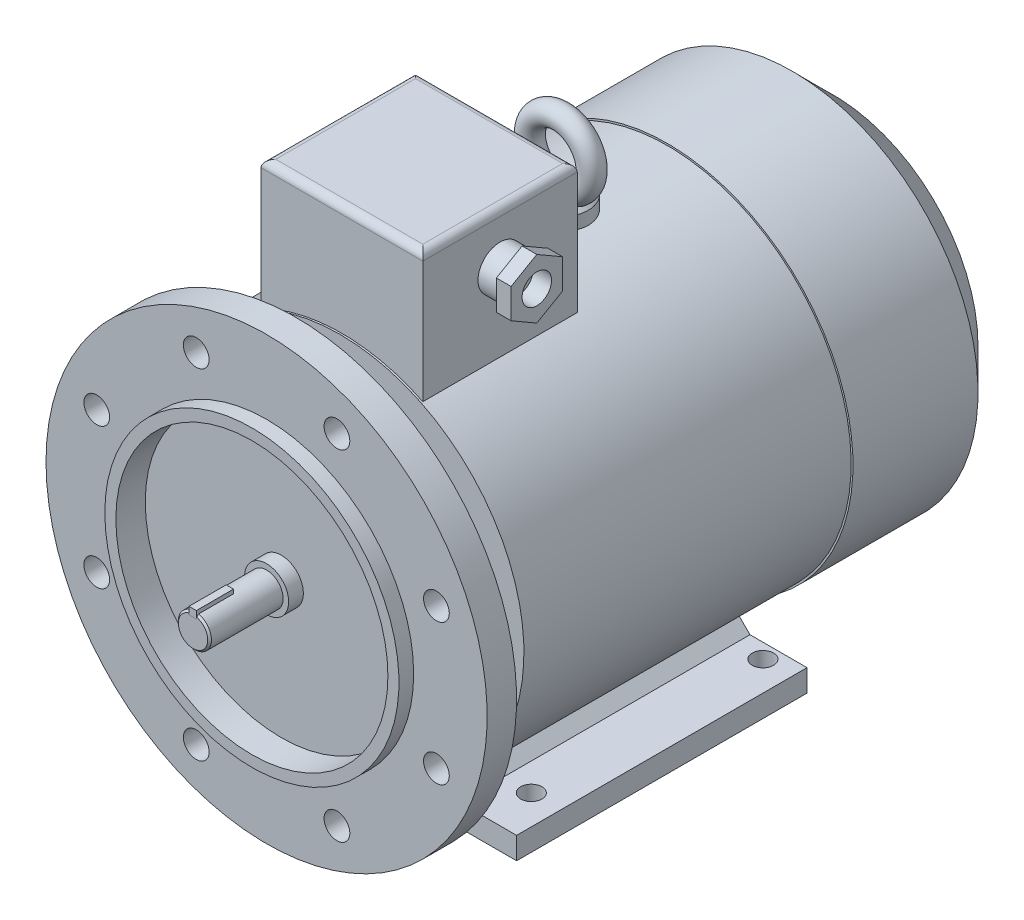
from build123d import *

# Parameters (mm, degrees)
SKETCH_1_R            = 4.5
EXTRUDE_1_DEPTH       = 20
CHAMFER_1_SIZE        = 0.5
SKETCH_2_W            = 2
SKETCH_2_H            = 2
EXTRUDE_2_DEPTH       = 0.1
EXTRUDE_2_DEPTH_BACK  = 10
SKETCH_3_R            = 6
EXTRUDE_3_DEPTH       = 4
CHAMFER_2_SIZE        = 0.5
SKETCH_4_R            = 40
SKETCH_4_R_2          = 37
EXTRUDE_4_DEPTH       = 8
SKETCH_5_R            = 60
EXTRUDE_5_DEPTH       = 4
EXTRUDE_5_DEPTH_BACK  = 4
SKETCH_6_R            = 3.5
CUT_EXTRUDE_1_DEPTH   = 29.1
SKETCH_7_R            = 42
EXTRUDE_6_DEPTH       = 12
SKETCH_8_R            = 50
EXTRUDE_7_DEPTH       = 89
SKETCH_9_R            = 50.5
EXTRUDE_8_DEPTH       = 45
CHAMFER_3_SIZE        = 11
EXTRUDE_9_DEPTH       = 79
CUT_EXTRUDE_2_REACH   = 112
SKETCH_12_R           = 2.9
SKETCH_13_W           = 44
SKETCH_13_H           = 42
EXTRUDE_10_DEPTH      = 80
FILLET_1_R            = 2
SKETCH_14_R           = 6
EXTRUDE_11_DEPTH      = 6
EXTRUDE_12_DEPTH      = 4
SKETCH_16_R           = 4
CUT_EXTRUDE_3_DEPTH   = 5
SKETCH_17_R           = 7.5
EXTRUDE_13_DEPTH      = 5
EXTRUDE_13_DEPTH_BACK = 6
CHAMFER_4_SIZE        = 2
SKETCH_21_R           = 3
SKETCH_22_R           = 37
SKETCH_22_R_2         = 6
CUT_EXTRUDE_4_DEPTH   = 4


with BuildPart() as part:
    # Эскиз1 → Вытянуть1 (new body)
    with BuildSketch(Plane.XY):
        Circle(SKETCH_1_R)
    extrude(amount=EXTRUDE_1_DEPTH)

    # Фаска1
    chamfer_1_edges = [part.edges().sort_by_distance(p)[0] for p in [
        (-4.5, 0, 20),
    ]]
    chamfer(chamfer_1_edges, length=CHAMFER_1_SIZE)

    # Эскиз2 → Вытянуть2 (add, two sides)
    with BuildSketch(Plane.XY.offset(20)) as extrude_2_sk:
        with Locations((0, 4.5)):
            Rectangle(SKETCH_2_W, SKETCH_2_H)
    extrude(amount=EXTRUDE_2_DEPTH)
    extrude(extrude_2_sk.sketch, amount=-EXTRUDE_2_DEPTH_BACK)

    # Эскиз3 → Вытянуть3 (add)
    with BuildSketch(Plane.XY):
        Circle(SKETCH_3_R)
    extrude(amount=-EXTRUDE_3_DEPTH)

    # Фаска2
    chamfer_2_edges = [part.edges().sort_by_distance(p)[0] for p in [
        (-6, 0, 0),
    ]]
    chamfer(chamfer_2_edges, length=CHAMFER_2_SIZE)



with BuildPart() as body_2:
    # Эскиз4 → Вытянуть4 (new body)
    with BuildSketch(Plane(origin=(0, 0, -4), x_dir=(-1, 0, 0), z_dir=(0, 0, -1))):
        Circle(SKETCH_4_R)
        Circle(SKETCH_4_R_2, mode=Mode.SUBTRACT)
    extrude(amount=-EXTRUDE_4_DEPTH)


with BuildPart() as part_1:
    add(part.part)

    add(body_2.part)  # Вытянуть5 merges body 2
    # Эскиз5 → Вытянуть5 (add, two sides)
    with BuildSketch(Plane(origin=(0, 0, -4), x_dir=(-1, 0, 0), z_dir=(0, 0, -1))) as extrude_5_sk:
        Circle(SKETCH_5_R)
    extrude(amount=EXTRUDE_5_DEPTH)
    extrude(extrude_5_sk.sketch, amount=-EXTRUDE_5_DEPTH_BACK)

    # Эскиз6 → Вырез-Вытянуть1 (cut, through all)
    with BuildSketch(Plane(origin=(0, 0, -8), x_dir=(-1, 0, 0), z_dir=(0, 0, -1))):
        with Locations((-19.134171618, 46.193976626)):
            Circle(SKETCH_6_R)
        with Locations((19.134171618, 46.193976626)):
            Circle(SKETCH_6_R)
        with Locations((46.193976626, 19.134171618)):
            Circle(SKETCH_6_R)
        with Locations((46.193976626, -19.134171618)):
            Circle(SKETCH_6_R)
        with Locations((19.134171618, -46.193976626)):
            Circle(SKETCH_6_R)
        with Locations((-19.134171618, -46.193976626)):
            Circle(SKETCH_6_R)
        with Locations((-46.193976626, -19.134171618)):
            Circle(SKETCH_6_R)
        with Locations((-46.193976626, 19.134171618)):
            Circle(SKETCH_6_R)
    extrude(amount=-CUT_EXTRUDE_1_DEPTH, mode=Mode.SUBTRACT)

    # Эскиз7 → Вытянуть6 (add)
    with BuildSketch(Plane(origin=(0, 0, -8), x_dir=(-1, 0, 0), z_dir=(0, 0, -1))):
        Circle(SKETCH_7_R)
    extrude(amount=EXTRUDE_6_DEPTH)

    # Эскиз8 → Вытянуть7 (add)
    with BuildSketch(Plane(origin=(0, 0, -20), x_dir=(-1, 0, 0), z_dir=(0, 0, -1))):
        Circle(SKETCH_8_R)
    extrude(amount=EXTRUDE_7_DEPTH)

    # Эскиз9 → Вытянуть8 (add)
    with BuildSketch(Plane(origin=(0, 0, -109), x_dir=(-1, 0, 0), z_dir=(0, 0, -1))):
        Circle(SKETCH_9_R)
    extrude(amount=EXTRUDE_8_DEPTH)

    # Фаска3
    chamfer_3_edges = [part_1.edges().sort_by_distance(p)[0] for p in [
        (50.5, 0, -154),
    ]]
    chamfer(chamfer_3_edges, length=CHAMFER_3_SIZE)

    # Эскиз11 → Вытянуть9 (add)
    with BuildSketch(Plane.XY.offset(-20)):
        Polygon((-48, -44), (-48, -50), (-30, -50), (-23.911649916, -43.911649916), (-25.248709702, -39.738903486), (-29.126058148, -40.640776774), (-32.485281374, -44), align=None)
        Polygon((48, -44), (48, -50), (30, -50), (23.911649916, -43.911649916), (23.911649916, -39.738903486), (29.126058148, -40.640776774), (32.485281374, -44), align=None)
    extrude(amount=-EXTRUDE_9_DEPTH)

    # Эскиз12 → Вырез-Вытянуть2 (cut, up to next)
    with BuildSketch(Plane.XZ.offset(50), mode=Mode.PRIVATE) as cut_extrude_2_sk1:
        with Locations((40, -32)):
            Circle(SKETCH_12_R)
    cut_extrude_2_tool1 = extrude(cut_extrude_2_sk1.sketch, amount=-CUT_EXTRUDE_2_REACH, mode=Mode.PRIVATE) & part_1.part
    add(cut_extrude_2_tool1.solids().sort_by_distance((40, -50, -32))[0], mode=Mode.SUBTRACT)
    # Эскиз12 → Вырез-Вытянуть2 (cut, up to next)
    with BuildSketch(Plane.XZ.offset(50), mode=Mode.PRIVATE) as cut_extrude_2_sk2:
        with Locations((-40, -32)):
            Circle(SKETCH_12_R)
    cut_extrude_2_tool2 = extrude(cut_extrude_2_sk2.sketch, amount=-CUT_EXTRUDE_2_REACH, mode=Mode.PRIVATE) & part_1.part
    add(cut_extrude_2_tool2.solids().sort_by_distance((-40, -50, -32))[0], mode=Mode.SUBTRACT)
    # Эскиз12 → Вырез-Вытянуть2 (cut, up to next)
    with BuildSketch(Plane.XZ.offset(50), mode=Mode.PRIVATE) as cut_extrude_2_sk3:
        with Locations((40, -95)):
            Circle(SKETCH_12_R)
    cut_extrude_2_tool3 = extrude(cut_extrude_2_sk3.sketch, amount=-CUT_EXTRUDE_2_REACH, mode=Mode.PRIVATE) & part_1.part
    add(cut_extrude_2_tool3.solids().sort_by_distance((40, -50, -95))[0], mode=Mode.SUBTRACT)
    # Эскиз12 → Вырез-Вытянуть2 (cut, up to next)
    with BuildSketch(Plane.XZ.offset(50), mode=Mode.PRIVATE) as cut_extrude_2_sk4:
        with Locations((-40, -95)):
            Circle(SKETCH_12_R)
    cut_extrude_2_tool4 = extrude(cut_extrude_2_sk4.sketch, amount=-CUT_EXTRUDE_2_REACH, mode=Mode.PRIVATE) & part_1.part
    add(cut_extrude_2_tool4.solids().sort_by_distance((-40, -50, -95))[0], mode=Mode.SUBTRACT)

    # Эскиз13 → Вытянуть10 (add)
    with BuildSketch(Plane(origin=(0, 0, 0), x_dir=(1, 0, 0), z_dir=(0, 1, 0))):
        with Locations((0, 41.5)):
            Rectangle(SKETCH_13_W, SKETCH_13_H)
    extrude(amount=EXTRUDE_10_DEPTH)

    # Скругление1
    fillet_1_edges = [part_1.edges().sort_by_distance(p)[0] for p in [
        (22, 80, -41.5),
        (0, 80, -62.5),
        (-22, 80, -41.5),
        (0, 80, -20.5),
    ]]
    fillet(fillet_1_edges, radius=FILLET_1_R)

    # Эскиз14 → Вытянуть11 (add)
    with BuildSketch(Plane(origin=(22, 0, 0), x_dir=(0, 0, -1), z_dir=(1, 0, 0))):
        with Locations(Location((41.5, 66, 0), (0, 0, 180))):  # turned: the seam where the file's is
            Circle(SKETCH_14_R)
    extrude(amount=EXTRUDE_11_DEPTH)

    # Эскиз15 → Вытянуть12 (add)
    with BuildSketch(Plane(origin=(28, 0, 0), x_dir=(0, 0, -1), z_dir=(1, 0, 0))):
        Polygon((41.5, 74.082903769), (34.5, 70.041451884), (34.5, 61.958548116), (41.5, 57.917096231), (48.5, 61.958548116), (48.5, 70.041451884), align=None)
    extrude(amount=EXTRUDE_12_DEPTH)

    # Эскиз16 → Вырез-Вытянуть3 (cut)
    with BuildSketch(Plane(origin=(32, 0, 0), x_dir=(0, 0, -1), z_dir=(1, 0, 0))):
        with Locations((41.5, 66)):
            Circle(SKETCH_16_R)
    extrude(amount=-CUT_EXTRUDE_3_DEPTH, mode=Mode.SUBTRACT)

    # Эскиз17 → Вытянуть13 (add, two sides)
    with BuildSketch(Plane(origin=(0, 50, 0), x_dir=(-1, 0, 0), z_dir=(0, 1, 0))) as extrude_13_sk:
        with Locations(Location((0, -80, 0), (0, 0, 270))):  # turned: the seam where the file's is
            Circle(SKETCH_17_R)
    extrude(amount=EXTRUDE_13_DEPTH)
    extrude(extrude_13_sk.sketch, amount=-EXTRUDE_13_DEPTH_BACK)

    # Фаска4
    chamfer_4_edges = [part_1.edges().sort_by_distance(p)[0] for p in [
        (0, 55, -72.5),
    ]]
    chamfer(chamfer_4_edges, length=CHAMFER_4_SIZE)

    # По траектории1: sweep along a path in Эскиз19
    with BuildLine(Plane.XY.offset(-80)) as sweep_1_path:
        CenterArc((0, 63), 8.5, 0, 360)
    # Эскиз21 → По траектории1 (sweep)
    with BuildSketch(Plane(origin=(0, 0, 0), x_dir=(0, 0, -1), z_dir=(1, 0, 0))):
        with Locations((80, 71.40369347)):
            Circle(SKETCH_21_R)
    sweep(path=sweep_1_path.line)

    # Эскиз22 → Вырез-Вытянуть4 (cut)
    with BuildSketch(Plane.XY):
        with Locations(Location((0, 0, 0), (0, 0, 180))):  # turned: the seam where the file's is
            Circle(SKETCH_22_R)
        Circle(SKETCH_22_R_2, mode=Mode.SUBTRACT)
    extrude(amount=-CUT_EXTRUDE_4_DEPTH, mode=Mode.SUBTRACT)


solid = part_1.part
